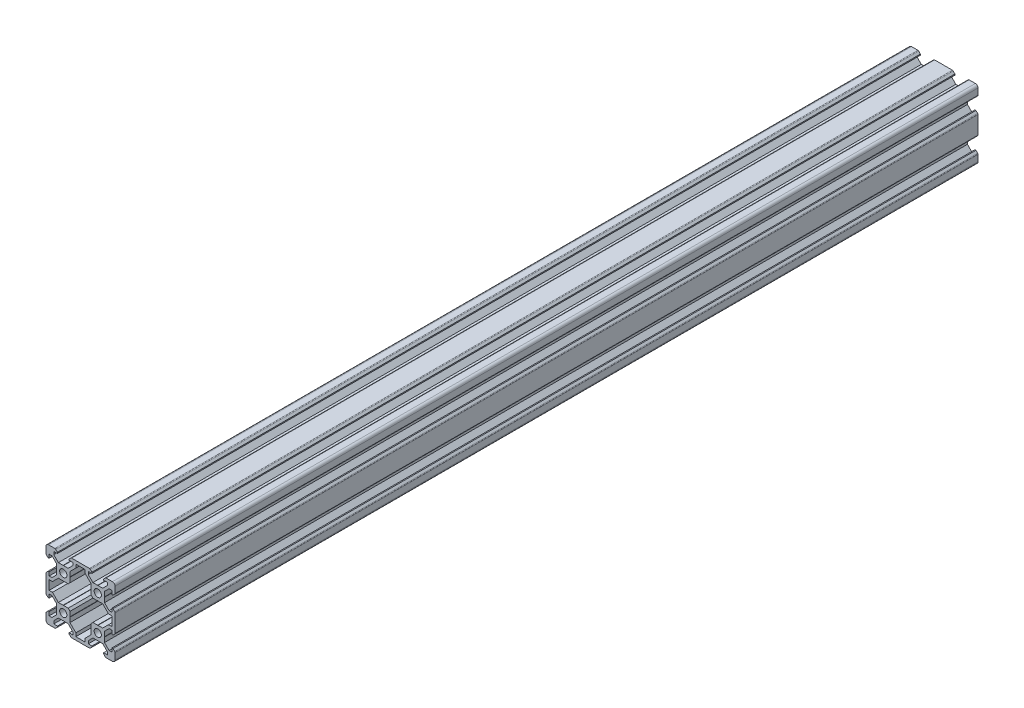
from build123d import *

# Parameters (mm, degrees)
SKETCH1_R           = 2.1
BOSS_EXTRUDE2_DEPTH = 500


with BuildPart() as part:
    # Sketch1 → Boss-Extrude2 (new body)
    with BuildSketch(Plane.XY):
        with BuildLine():
            Line((-8.5, 10), (-4.862792737, 10))
            ThreePointArc((-4.862792737, 10), (-4.598292737, 9.947387679), (-4.374060464, 9.797560464))
            Line((-4.374060464, 9.797560464), (-3.3865, 8.81))
            Line((-3.3865, 8.81), (-3.3865, 8.2))
            Line((-3.3865, 8.2), (-5.5, 8.2))
            Line((-5.5, 8.2), (-5.5, 6.561))
            Line((-5.5, 6.561), (-2.8395, 3.9005))
            Line((-2.8395, 3.9005), (-0.1, 3.9005))
            Line((-0.1, 3.9005), (0, 3.8005))
            Line((0, 3.8005), (0.1, 3.9005))
            Line((0.1, 3.9005), (2.8395, 3.9005))
            Line((2.8395, 3.9005), (5.5, 6.561))
            Line((5.5, 6.561), (5.5, 8.2))
            Line((5.5, 8.2), (3.3865, 8.2))
            Line((3.3865, 8.2), (3.3865, 8.81))
            Line((3.3865, 8.81), (4.374060464, 9.797560464))
            ThreePointArc((4.374060464, 9.797560464), (4.598292737, 9.947387679), (4.862792737, 10))
            Line((4.862792737, 10), (15.137207263, 10))
            ThreePointArc((15.137207263, 10), (15.401707263, 9.947387679), (15.625939536, 9.797560464))
            Line((15.625939536, 9.797560464), (16.6135, 8.81))
            Line((16.6135, 8.81), (16.6135, 8.2))
            Line((16.6135, 8.2), (14.5, 8.2))
            Line((14.5, 8.2), (14.5, 6.561))
            Line((14.5, 6.561), (17.1605, 3.9005))
            Line((17.1605, 3.9005), (19.9, 3.9005))
            Line((19.9, 3.9005), (20, 3.8005))
            Line((20, 3.8005), (20.1, 3.9005))
            Line((20.1, 3.9005), (22.8395, 3.9005))
            Line((22.8395, 3.9005), (25.5, 6.561))
            Line((25.5, 6.561), (25.5, 8.2))
            Line((25.5, 8.2), (23.3865, 8.2))
            Line((23.3865, 8.2), (23.3865, 8.81))
            Line((23.3865, 8.81), (24.374060464, 9.797560464))
            ThreePointArc((24.374060464, 9.797560464), (24.598292737, 9.947387679), (24.862792737, 10))
            Line((24.862792737, 10), (28.5, 10))
            ThreePointArc((28.5, 10), (29.560660172, 9.560660172), (30, 8.5))
            Line((30, 8.5), (30, 4.862792737))
            ThreePointArc((30, 4.862792737), (29.947387679, 4.598292737), (29.797560464, 4.374060464))
            Line((29.797560464, 4.374060464), (28.81, 3.3865))
            Line((28.81, 3.3865), (28.2, 3.3865))
            Line((28.2, 3.3865), (28.2, 5.5))
            Line((28.2, 5.5), (26.561, 5.5))
            Line((26.561, 5.5), (23.9005, 2.8395))
            Line((23.9005, 2.8395), (23.9005, 0.1))
            Line((23.9005, 0.1), (23.8005, 0))
            Line((23.8005, 0), (23.9005, -0.1))
            Line((23.9005, -0.1), (23.9005, -2.8395))
            Line((23.9005, -2.8395), (26.561, -5.5))
            Line((26.561, -5.5), (28.2, -5.5))
            Line((28.2, -5.5), (28.2, -3.3865))
            Line((28.2, -3.3865), (28.81, -3.3865))
            Line((28.81, -3.3865), (29.797560464, -4.374060464))
            ThreePointArc((29.797560464, -4.374060464), (29.947387679, -4.598292737), (30, -4.862792737))
            Line((30, -4.862792737), (30, -15.137207263))
            ThreePointArc((30, -15.137207263), (29.947387679, -15.401707263), (29.797560464, -15.625939536))
            Line((29.797560464, -15.625939536), (28.81, -16.6135))
            Line((28.81, -16.6135), (28.2, -16.6135))
            Line((28.2, -16.6135), (28.2, -14.5))
            Line((28.2, -14.5), (26.561, -14.5))
            Line((26.561, -14.5), (23.9005, -17.1605))
            Line((23.9005, -17.1605), (23.9005, -19.9))
            Line((23.9005, -19.9), (23.8005, -20))
            Line((23.8005, -20), (23.9005, -20.1))
            Line((23.9005, -20.1), (23.9005, -22.8395))
            Line((23.9005, -22.8395), (26.561, -25.5))
            Line((26.561, -25.5), (28.2, -25.5))
            Line((28.2, -25.5), (28.2, -23.3865))
            Line((28.2, -23.3865), (28.81, -23.3865))
            Line((28.81, -23.3865), (29.797560464, -24.374060464))
            ThreePointArc((29.797560464, -24.374060464), (29.947387679, -24.598292737), (30, -24.862792737))
            Line((30, -24.862792737), (30, -28.5))
            ThreePointArc((30, -28.5), (29.560660172, -29.560660172), (28.5, -30))
            Line((28.5, -30), (24.862792737, -30))
            ThreePointArc((24.862792737, -30), (24.598292737, -29.947387679), (24.374060464, -29.797560464))
            Line((24.374060464, -29.797560464), (23.3865, -28.81))
            Line((23.3865, -28.81), (23.3865, -28.2))
            Line((23.3865, -28.2), (25.5, -28.2))
            Line((25.5, -28.2), (25.5, -26.561))
            Line((25.5, -26.561), (22.8395, -23.9005))
            Line((22.8395, -23.9005), (20.1, -23.9005))
            Line((20.1, -23.9005), (20, -23.8005))
            Line((20, -23.8005), (19.9, -23.9005))
            Line((19.9, -23.9005), (17.1605, -23.9005))
            Line((17.1605, -23.9005), (14.5, -26.561))
            Line((14.5, -26.561), (14.5, -28.2))
            Line((14.5, -28.2), (16.6135, -28.2))
            Line((16.6135, -28.2), (16.6135, -28.81))
            Line((16.6135, -28.81), (15.625939536, -29.797560464))
            ThreePointArc((15.625939536, -29.797560464), (15.401707263, -29.947387679), (15.137207263, -30))
            Line((15.137207263, -30), (4.862792737, -30))
            ThreePointArc((4.862792737, -30), (4.598292737, -29.947387679), (4.374060464, -29.797560464))
            Line((4.374060464, -29.797560464), (3.3865, -28.81))
            Line((3.3865, -28.81), (3.3865, -28.2))
            Line((3.3865, -28.2), (5.5, -28.2))
            Line((5.5, -28.2), (5.5, -26.561))
            Line((5.5, -26.561), (2.8395, -23.9005))
            Line((2.8395, -23.9005), (0.1, -23.9005))
            Line((0.1, -23.9005), (0, -23.8005))
            Line((0, -23.8005), (-0.1, -23.9005))
            Line((-0.1, -23.9005), (-2.8395, -23.9005))
            Line((-2.8395, -23.9005), (-5.5, -26.561))
            Line((-5.5, -26.561), (-5.5, -28.2))
            Line((-5.5, -28.2), (-3.3865, -28.2))
            Line((-3.3865, -28.2), (-3.3865, -28.81))
            Line((-3.3865, -28.81), (-4.374060464, -29.797560464))
            ThreePointArc((-4.374060464, -29.797560464), (-4.598292737, -29.947387679), (-4.862792737, -30))
            Line((-4.862792737, -30), (-8.5, -30))
            ThreePointArc((-8.5, -30), (-9.560660172, -29.560660172), (-10, -28.5))
            Line((-10, -28.5), (-10, -24.862792737))
            ThreePointArc((-10, -24.862792737), (-9.947387679, -24.598292737), (-9.797560464, -24.374060464))
            Line((-9.797560464, -24.374060464), (-8.81, -23.3865))
            Line((-8.81, -23.3865), (-8.2, -23.3865))
            Line((-8.2, -23.3865), (-8.2, -25.5))
            Line((-8.2, -25.5), (-6.561, -25.5))
            Line((-6.561, -25.5), (-3.9005, -22.8395))
            Line((-3.9005, -22.8395), (-3.9005, -20.1))
            Line((-3.9005, -20.1), (-3.8005, -20))
            Line((-3.8005, -20), (-3.9005, -19.9))
            Line((-3.9005, -19.9), (-3.9005, -17.1605))
            Line((-3.9005, -17.1605), (-6.561, -14.5))
            Line((-6.561, -14.5), (-8.2, -14.5))
            Line((-8.2, -14.5), (-8.2, -16.6135))
            Line((-8.2, -16.6135), (-8.81, -16.6135))
            Line((-8.81, -16.6135), (-9.797560464, -15.625939536))
            ThreePointArc((-9.797560464, -15.625939536), (-9.947387679, -15.401707263), (-10, -15.137207263))
            Line((-10, -15.137207263), (-10, -4.862792737))
            ThreePointArc((-10, -4.862792737), (-9.947387679, -4.598292737), (-9.797560464, -4.374060464))
            Line((-9.797560464, -4.374060464), (-8.81, -3.3865))
            Line((-8.81, -3.3865), (-8.2, -3.3865))
            Line((-8.2, -3.3865), (-8.2, -5.5))
            Line((-8.2, -5.5), (-6.561, -5.5))
            Line((-6.561, -5.5), (-3.9005, -2.8395))
            Line((-3.9005, -2.8395), (-3.9005, -0.1))
            Line((-3.9005, -0.1), (-3.8005, 0))
            Line((-3.8005, 0), (-3.9005, 0.1))
            Line((-3.9005, 0.1), (-3.9005, 2.8395))
            Line((-3.9005, 2.8395), (-6.561, 5.5))
            Line((-6.561, 5.5), (-8.2, 5.5))
            Line((-8.2, 5.5), (-8.2, 3.3865))
            Line((-8.2, 3.3865), (-8.81, 3.3865))
            Line((-8.81, 3.3865), (-9.797560464, 4.374060464))
            ThreePointArc((-9.797560464, 4.374060464), (-9.947387679, 4.598292737), (-10, 4.862792737))
            Line((-10, 4.862792737), (-10, 8.5))
            ThreePointArc((-10, 8.5), (-9.560660172, 9.560660172), (-8.5, 10))
        make_face()
        Circle(SKETCH1_R, mode=Mode.SUBTRACT)
        with Locations((0, -20)):
            Circle(SKETCH1_R, mode=Mode.SUBTRACT)
        with Locations((20, 0)):
            Circle(SKETCH1_R, mode=Mode.SUBTRACT)
        with Locations((20, -20)):
            Circle(SKETCH1_R, mode=Mode.SUBTRACT)
        Polygon((-8.2, -12.7), (-8.2, -7.3), (-6.239, -7.3), (-5.5, -6.561), (-2.8395, -3.9005), (-0.1, -3.9005), (0, -3.8005), (0.1, -3.9005), (2.8395, -3.9005), (3.9005, -2.8395), (3.9005, -0.1), (3.8005, 0), (3.9005, 0.1), (3.9005, 2.8395), (6.561, 5.5), (7.3, 6.239), (7.3, 8.2), (10, 8.2), (12.7, 8.2), (12.7, 6.239), (13.439, 5.5), (16.0995, 2.8395), (16.0995, 0.1), (16.1995, 0), (16.0995, -0.1), (16.0995, -2.8395), (17.1605, -3.9005), (19.9, -3.9005), (20, -3.8005), (20.1, -3.9005), (22.8395, -3.9005), (25.5, -6.561), (26.239, -7.3), (28.2, -7.3), (28.2, -12.7), (26.239, -12.7), (25.5, -13.439), (22.8395, -16.0995), (20.1, -16.0995), (20, -16.1995), (19.9, -16.0995), (17.1605, -16.0995), (16.0995, -17.1605), (16.0995, -19.9), (16.1995, -20), (16.0995, -20.1), (16.0995, -22.8395), (13.439, -25.5), (12.7, -26.239), (12.7, -28.2), (10, -28.2), (7.3, -28.2), (7.3, -26.239), (6.561, -25.5), (3.9005, -22.8395), (3.9005, -20.1), (3.8005, -20), (3.9005, -19.9), (3.9005, -17.1605), (2.8395, -16.0995), (0.1, -16.0995), (0, -16.1995), (-0.1, -16.0995), (-2.8395, -16.0995), (-5.5, -13.439), (-6.239, -12.7), align=None, mode=Mode.SUBTRACT)
    extrude(amount=BOSS_EXTRUDE2_DEPTH)


solid = part.part
